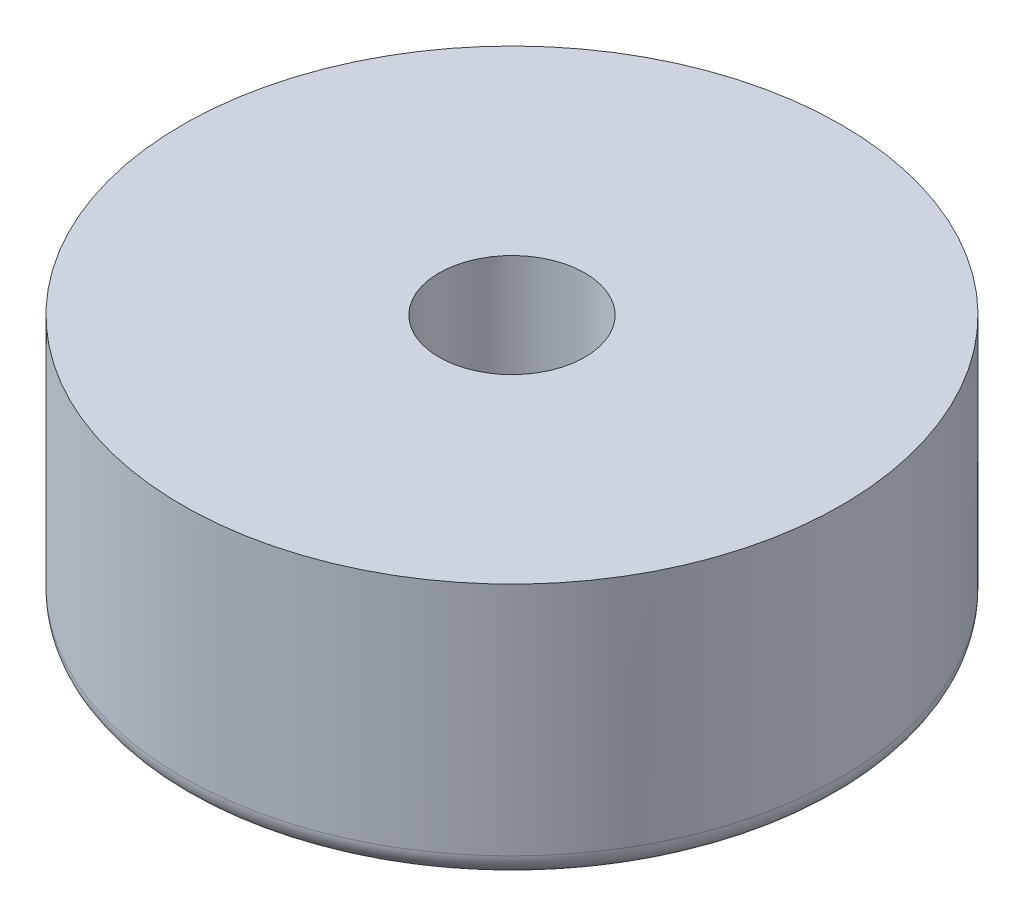
from build123d import *

# Parameters (mm, degrees)
FILLET1_R = 0.5


with BuildPart() as part:
    # Sketch1 → Revolve1 (revolve)
    with BuildSketch(Plane.XY):
        Polygon((-1.55, 0), (-7, 0), (-7, -5.5), (-4, -5.5), (-4, -3.373831776), (-1.55, -3.373831776), align=None)
    revolve(axis=Axis((0, 0, 0), (0, 1, 0)))

    # Fillet1
    fillet1_edges = [part.edges().sort_by_distance(p)[0] for p in [
        (4, -5.5, 0),
        (7, -5.5, 0),
    ]]
    fillet(fillet1_edges, radius=FILLET1_R)


solid = part.part
